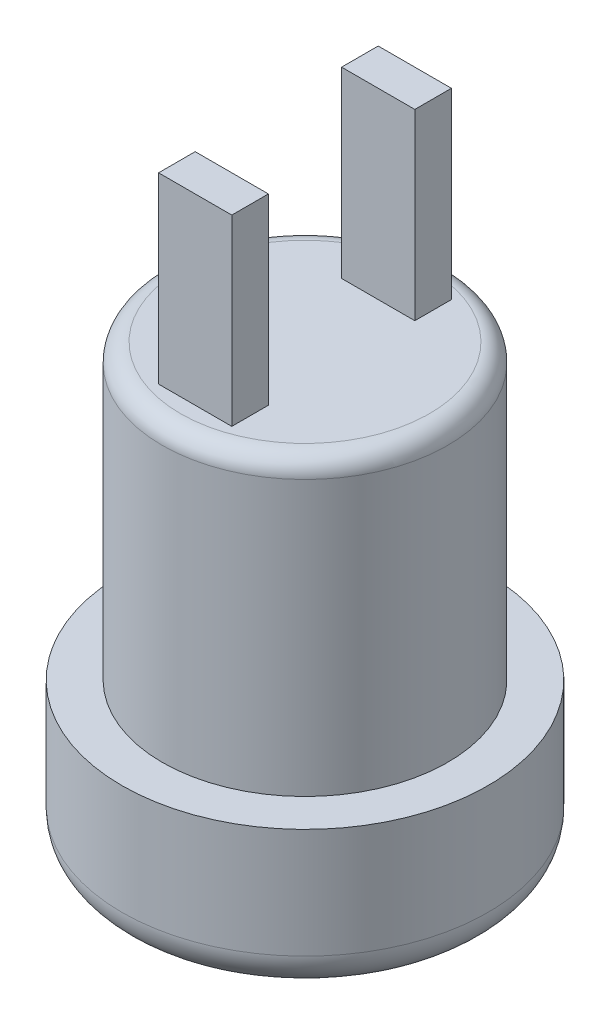
from build123d import *

# Parameters (mm, degrees)
ESQUISSE1_R             = 5
BOSS_EXTRU_1_DEPTH      = 4
ESQUISSE2_R             = 3.9
BOSS_EXTRU_2_DEPTH      = 8
CONG_1_R                = 1
ESQUISSE3_R             = 3
ENL_V_MAT_EXTRU_2_DEPTH = 6
ESQUISSE4_W             = 2
ESQUISSE4_H             = 1
BOSS_EXTRU_3_DEPTH      = 5
CONG_2_R                = 0.5


with BuildPart() as part:
    # Esquisse1 → Boss.-Extru.1 (new body)
    with BuildSketch(Plane(origin=(0, 0, 0), x_dir=(1, 0, 0), z_dir=(0, 1, 0))):
        Circle(ESQUISSE1_R)
    extrude(amount=BOSS_EXTRU_1_DEPTH)

    # Esquisse2 → Boss.-Extru.2 (add)
    with BuildSketch(Plane(origin=(0, 4, 0), x_dir=(1, 0, 0), z_dir=(0, 1, 0))):
        Circle(ESQUISSE2_R)
    extrude(amount=BOSS_EXTRU_2_DEPTH)

    # Congé1
    cong_1_edges = [part.edges().sort_by_distance(p)[0] for p in [
        (-5, 0, 0),
    ]]
    fillet(cong_1_edges, radius=CONG_1_R)

    # Esquisse3 → Enlèv. mat.-Extru.2 (cut)
    with BuildSketch(Plane.XZ):
        Circle(ESQUISSE3_R)
    extrude(amount=-ENL_V_MAT_EXTRU_2_DEPTH, mode=Mode.SUBTRACT)

    # Esquisse4 → Boss.-Extru.3 (add)
    with BuildSketch(Plane(origin=(0, 12, 0), x_dir=(1, 0, 0), z_dir=(0, 1, 0))):
        with Locations((0, -2.5)):
            Rectangle(ESQUISSE4_W, ESQUISSE4_H)
        with Locations((0, 2.5)):
            Rectangle(ESQUISSE4_W, ESQUISSE4_H)
    extrude(amount=BOSS_EXTRU_3_DEPTH)

    # Congé2
    cong_2_edges = [part.edges().sort_by_distance(p)[0] for p in [
        (-3.9, 12, 0),
    ]]
    fillet(cong_2_edges, radius=CONG_2_R)


solid = part.part
